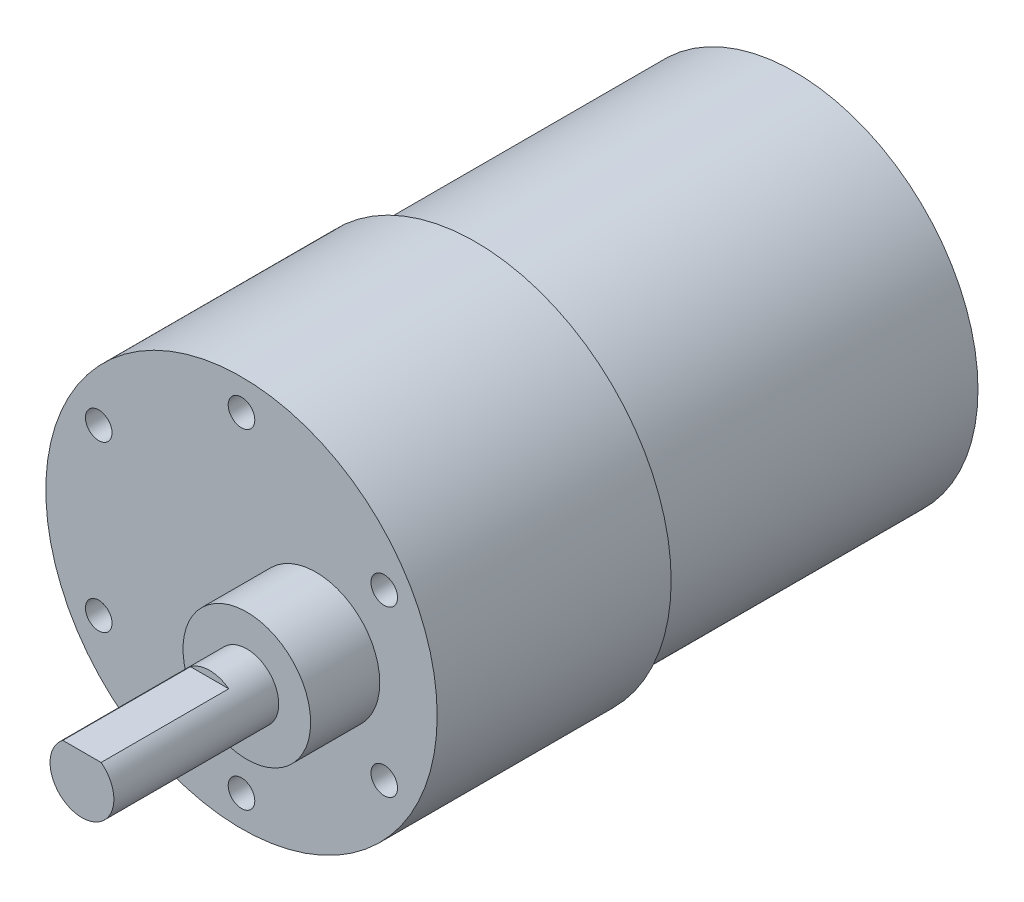
from build123d import *

# Parameters (mm, degrees)
SKETCH1_R                 = 18.4
BOSS_EXTRUDE1_DEPTH       = 22
M3X0_5_TAPPED_HOLE1_D     = 2.5
M3X0_5_TAPPED_HOLE1_DEPTH = 7.62
M3X0_5_TAPPED_HOLE1_TIP   = 0.751075774
SKETCH6_R                 = 17.25
BOSS_EXTRUDE2_DEPTH       = 30
SKETCH7_R                 = 3
BOSS_EXTRUDE3_DEPTH       = 22
CUT_EXTRUDE1_DEPTH        = 12
SKETCH9_R                 = 6
BOSS_EXTRUDE4_DEPTH       = 6.5


with BuildPart() as part:
    # Sketch1 → Boss-Extrude1 (new body)
    with BuildSketch(Plane.XY):
        Circle(SKETCH1_R)
    extrude(amount=BOSS_EXTRUDE1_DEPTH)

    # M3x0.5 Tapped Hole1
    with Locations(Plane.XY.offset(22)):
        with Locations((-13.423393759, 7.75), (0, 15.5), (13.423393759, 7.75), (13.423393759, -7.75), (0, -15.5), (-13.423393759, -7.75)):
            Hole(M3X0_5_TAPPED_HOLE1_D / 2, depth=M3X0_5_TAPPED_HOLE1_DEPTH)
            with Locations((0, 0, -(M3X0_5_TAPPED_HOLE1_DEPTH + M3X0_5_TAPPED_HOLE1_TIP / 2))):  # 118° drill point
                Cone(0, M3X0_5_TAPPED_HOLE1_D / 2, M3X0_5_TAPPED_HOLE1_TIP, mode=Mode.SUBTRACT)

    # Sketch6 → Boss-Extrude2 (add)
    with BuildSketch(Plane(origin=(0, 0, 0), x_dir=(-1, 0, 0), z_dir=(0, 0, -1))):
        Circle(SKETCH6_R)
    extrude(amount=BOSS_EXTRUDE2_DEPTH)

    # Sketch7 → Boss-Extrude3 (add)
    with BuildSketch(Plane.XY.offset(22)):
        with Locations((7, 0)):
            Circle(SKETCH7_R)
    extrude(amount=BOSS_EXTRUDE3_DEPTH)

    # Sketch8 → Cut-Extrude1 (cut)
    with BuildSketch(Plane.XY.offset(44)):
        with BuildLine():
            Line((5.2, 2.4), (8.8, 2.4))
            ThreePointArc((8.8, 2.4), (7, 3), (5.2, 2.4))
        make_face()
    extrude(amount=-CUT_EXTRUDE1_DEPTH, mode=Mode.SUBTRACT)

    # Sketch9 → Boss-Extrude4 (add)
    with BuildSketch(Plane.XY.offset(22)):
        with Locations((7, 0)):
            Circle(SKETCH9_R)
    extrude(amount=BOSS_EXTRUDE4_DEPTH)


solid = part.part
